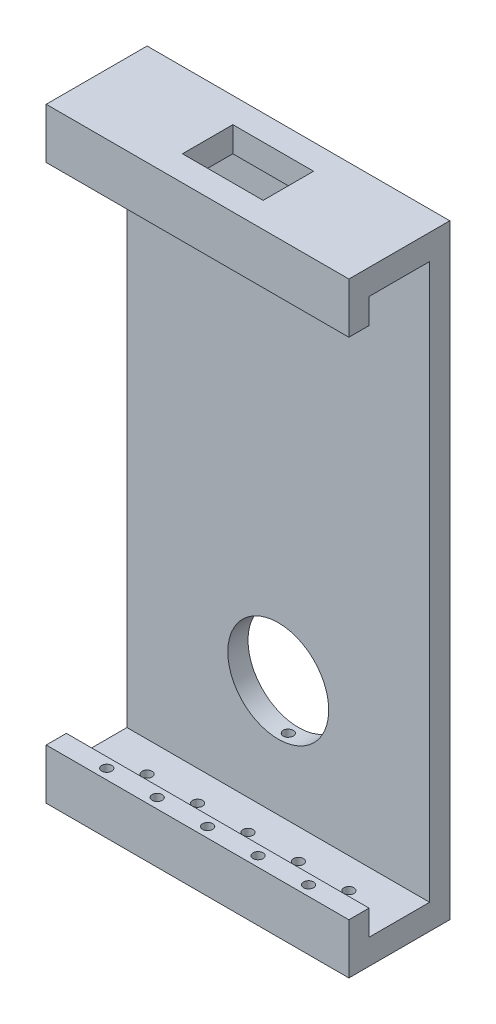
from build123d import *

# Parameters (mm, degrees)
ESQUISSE1_W                = 60
ESQUISSE1_H                = 120
BOSS_EXTRU_1_DEPTH         = 20
ENL_V_MAT_EXTRU_1_DEPTH    = 61
ESQUISSE3_W                = 16
ESQUISSE3_H                = 10
ENL_V_MAT_EXTRU_3_DEPTH    = 5
ESQUISSE4_R                = 10
ENL_V_MAT_EXTRU_4_DEPTH    = 21
ESQUISSE5_R                = 1
ENL_V_MAT_EXTRU_5_DEPTH    = 20
R_P_TITION_LIN_AIRE1_COUNT = 3
R_P_TITION_LIN_AIRE1_PITCH = 10
R_P_TITION_LIN_AIRE2_COUNT = 3
R_P_TITION_LIN_AIRE2_PITCH = 10


with BuildPart() as part:
    # Esquisse1 → Boss.-Extru.1 (new body)
    with BuildSketch(Plane.XY):
        with Locations((38.463255814, 60)):
            Rectangle(ESQUISSE1_W, ESQUISSE1_H)
    extrude(amount=BOSS_EXTRU_1_DEPTH)

    # Esquisse2 → Enlèv. mat.-Extru.1 (cut, through all)
    with BuildSketch(Plane(origin=(68.463255814, 0, 0), x_dir=(0, 0, -1), z_dir=(1, 0, 0))):
        Polygon((-20, 110), (-16, 110), (-16, 115), (-4, 115), (-4, 5), (-16, 5), (-16, 10), (-20, 10), align=None)
    extrude(amount=-ENL_V_MAT_EXTRU_1_DEPTH, mode=Mode.SUBTRACT)

    # Esquisse3 → Enlèv. mat.-Extru.3 (cut)
    with BuildSketch(Plane(origin=(0, 120, 0), x_dir=(1, 0, 0), z_dir=(0, 1, 0))):
        with Locations((38.463255814, -10)):
            Rectangle(ESQUISSE3_W, ESQUISSE3_H)
    extrude(amount=-ENL_V_MAT_EXTRU_3_DEPTH, mode=Mode.SUBTRACT)

    # Esquisse4 → Enlèv. mat.-Extru.4 (cut, through all)
    with BuildSketch(Plane(origin=(0, 0, 0), x_dir=(-1, 0, 0), z_dir=(0, 0, -1))):
        with Locations((-38.463255814, 28)):
            Circle(ESQUISSE4_R)
    extrude(amount=-ENL_V_MAT_EXTRU_4_DEPTH, mode=Mode.SUBTRACT)

    # Esquisse5 → Enlèv. mat.-Extru.5 (cut)
    with BuildSketch(Plane.XZ):
        with Locations((38.463255814, 18)):
            Circle(ESQUISSE5_R)
        with Locations((38.463255814, 2)):
            Circle(ESQUISSE5_R)
        with Locations((38.463255814, 10)):
            Circle(ESQUISSE5_R)
    enl_v_mat_extru_5 = extrude(amount=-ENL_V_MAT_EXTRU_5_DEPTH, mode=Mode.SUBTRACT)

    # Répétition linéaire1: Enlèv. mat.-Extru.5 ×3
    with Locations(*[(i * R_P_TITION_LIN_AIRE1_PITCH, 0, 0) for i in range(1, R_P_TITION_LIN_AIRE1_COUNT)]):
        add(enl_v_mat_extru_5, mode=Mode.SUBTRACT)

    # Répétition linéaire2: Enlèv. mat.-Extru.5 ×3
    with Locations(*[(-i * R_P_TITION_LIN_AIRE2_PITCH, 0, 0) for i in range(1, R_P_TITION_LIN_AIRE2_COUNT)]):
        add(enl_v_mat_extru_5, mode=Mode.SUBTRACT)


solid = part.part
